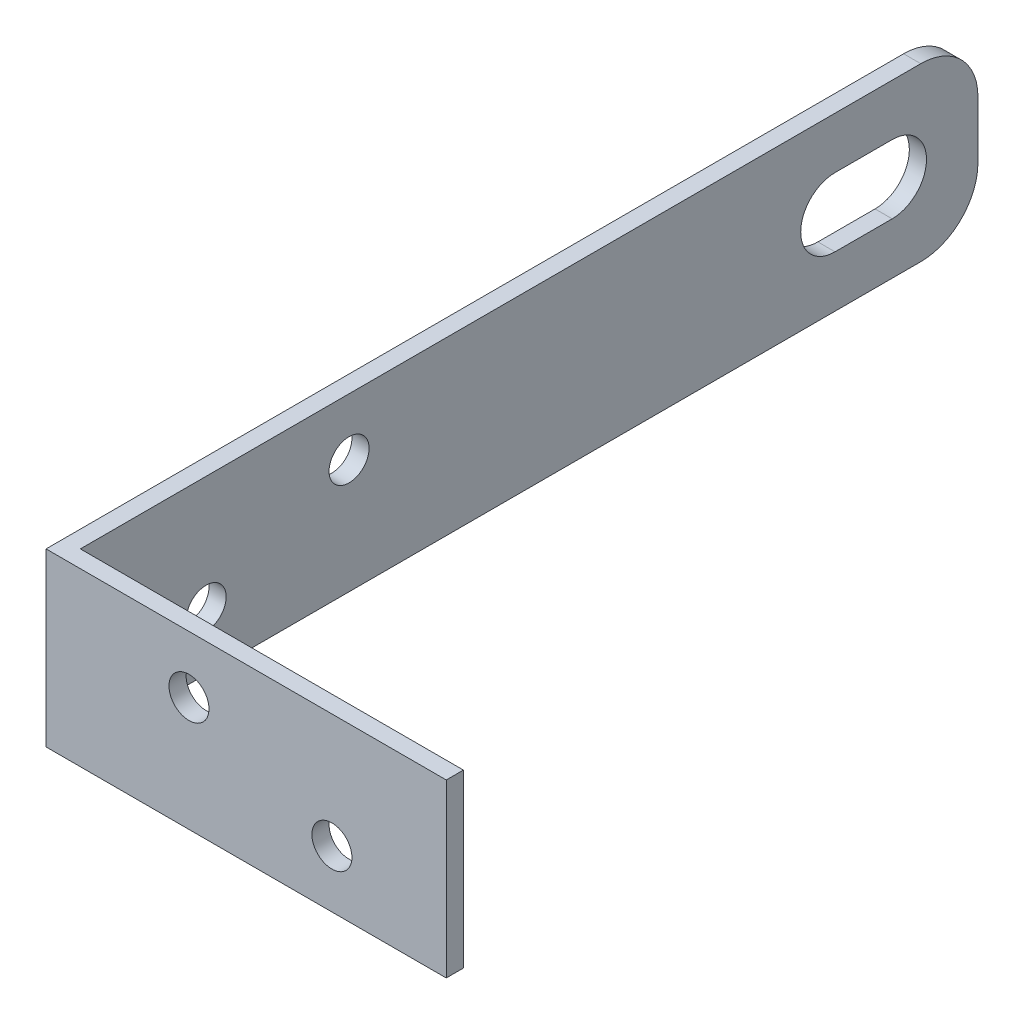
from build123d import *

# Parameters (mm, degrees)
EXTRUDE_1_DEPTH     = 30
SKETCH_2_R          = 3.5
CUT_EXTRUDE_1_DEPTH = 71
SKETCH_3_R          = 3.5
CUT_EXTRUDE_2_DEPTH = 161
CUT_EXTRUDE_3_DEPTH = 71


with BuildPart() as part:
    # Эскиз1 → Вытянуть-Тонкостенный1 (new body)
    with BuildSketch(Plane(origin=(0, 0, 0), x_dir=(1, 0, 0), z_dir=(0, 1, 0))):
        Polygon((0, 160), (0, 120), (0, 0), (70, 0), (70, 3), (3, 3), (3, 120), (3, 160), align=None)
    extrude(amount=EXTRUDE_1_DEPTH)

    # Эскиз2 → Вырез-Вытянуть1 (cut, through all)
    with BuildSketch(Plane.ZY):
        with Locations((-50, 20)):
            Circle(SKETCH_2_R)
        with Locations((-25, 10)):
            Circle(SKETCH_2_R)
    extrude(amount=-CUT_EXTRUDE_1_DEPTH, mode=Mode.SUBTRACT)

    # Эскиз3 → Вырез-Вытянуть2 (cut, through all)
    with BuildSketch(Plane.XY):
        with Locations((25, 20)):
            Circle(SKETCH_3_R)
        with Locations((50, 10)):
            Circle(SKETCH_3_R)
    extrude(amount=-CUT_EXTRUDE_2_DEPTH, mode=Mode.SUBTRACT)

    # Эскиз4 → Вырез-Вытянуть3 (cut, through all)
    with BuildSketch(Plane.ZY):
        with BuildLine():
            Line((-145, 21), (-135, 21))
            ThreePointArc((-135, 21), (-129, 15), (-135, 9))
            Line((-135, 9), (-145, 9))
            ThreePointArc((-145, 9), (-151, 15), (-145, 21))
        make_face()
        with BuildLine():
            Line((-160, 20), (-160, 30))
            Line((-160, 30), (-150, 30))
            ThreePointArc((-150, 30), (-157.071067812, 27.071067812), (-160, 20))
        make_face()
        with BuildLine():
            Line((-160, 10), (-160, 0))
            Line((-160, 0), (-150, 0))
            ThreePointArc((-150, 0), (-157.071067812, 2.928932188), (-160, 10))
        make_face()
    extrude(amount=-CUT_EXTRUDE_3_DEPTH, mode=Mode.SUBTRACT)


solid = part.part
